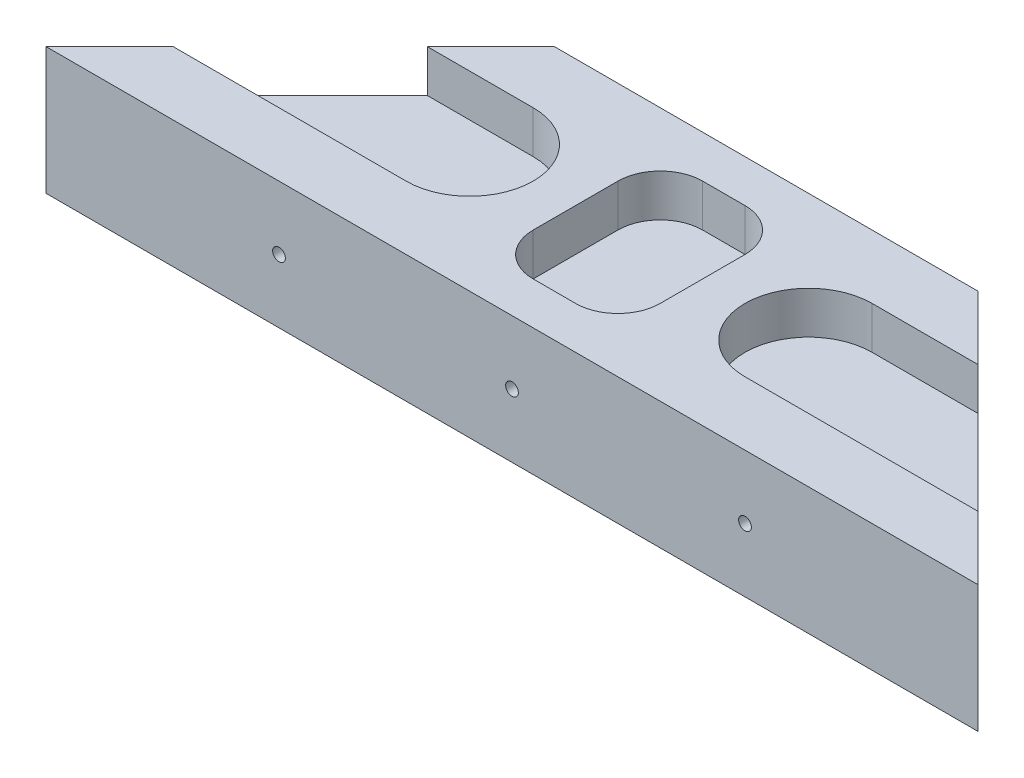
from build123d import *

# Parameters (mm, degrees)
BOSS_EXTRUDE1_DEPTH = 15
CUT_EXTRUDE1_DEPTH  = 5
SKETCH3_R           = 0.75
CUT_EXTRUDE2_DEPTH  = 30
CUT_EXTRUDE3_DEPTH  = 5


with BuildPart() as part:
    # Sketch1 → Boss-Extrude1 (new body)
    with BuildSketch(Plane(origin=(0, 0, 0), x_dir=(1, 0, 0), z_dir=(0, 1, 0))):
        Polygon((0, 0), (110, 0), (80, 30), (30, 30), align=None)
    extrude(amount=BOSS_EXTRUDE1_DEPTH)

    # Sketch2 → Cut-Extrude1 (cut)
    with BuildSketch(Plane(origin=(0, 15, 0), x_dir=(1, 0, 0), z_dir=(0, 1, 0))):
        with BuildLine():
            Line((-5, 22.5), (35, 22.5))
            ThreePointArc((35, 22.5), (42.5, 15), (35, 7.5))
            Line((35, 7.5), (-5, 7.5))
            ThreePointArc((-5, 7.5), (-12.5, 15), (-5, 22.5))
        make_face()
        with BuildLine():
            Line((115, 22.5), (75, 22.5))
            ThreePointArc((75, 22.5), (67.5, 15), (75, 7.5))
            Line((75, 7.5), (115, 7.5))
            ThreePointArc((115, 7.5), (122.5, 15), (115, 22.5))
        make_face()
    extrude(amount=-CUT_EXTRUDE1_DEPTH, mode=Mode.SUBTRACT)

    # Sketch3 → Cut-Extrude2 (cut)
    with BuildSketch(Plane.XY):
        with Locations((27.5, 7.5)):
            Circle(SKETCH3_R)
        with Locations((55, 7.5)):
            Circle(SKETCH3_R)
        with Locations((82.5, 7.5)):
            Circle(SKETCH3_R)
    extrude(amount=-CUT_EXTRUDE2_DEPTH, mode=Mode.SUBTRACT)

    # Sketch4 → Cut-Extrude3 (cut)
    with BuildSketch(Plane(origin=(0, 15, 0), x_dir=(1, 0, 0), z_dir=(0, 1, 0))):
        with BuildLine():
            Line((52.5, 25), (57.5, 25))
            ThreePointArc((57.5, 25), (61.035533906, 23.535533906), (62.5, 20))
            Line((62.5, 20), (62.5, 10))
            ThreePointArc((62.5, 10), (61.035533906, 6.464466094), (57.5, 5))
            Line((57.5, 5), (52.5, 5))
            ThreePointArc((52.5, 5), (48.964466094, 6.464466094), (47.5, 10))
            Line((47.5, 10), (47.5, 20))
            ThreePointArc((47.5, 20), (48.964466094, 23.535533906), (52.5, 25))
        make_face()
    extrude(amount=-CUT_EXTRUDE3_DEPTH, mode=Mode.SUBTRACT)


solid = part.part
